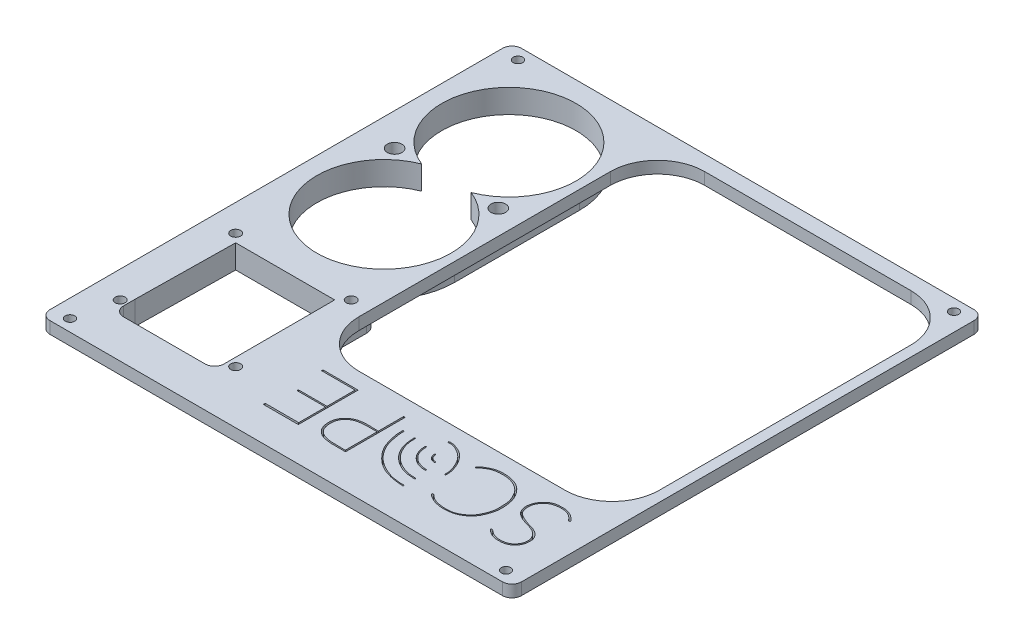
from build123d import *

# Parameters (mm, degrees)
SKETCH1_W           = 100
SKETCH1_H           = 100
BOSS_EXTRUDE1_DEPTH = 2.54
FILLET1_R           = 2
SKETCH5_R           = 1.55
SKETCH5_R_2         = 1.05000044
CUT_EXTRUDE1_DEPTH  = 71.756283113
SKETCH5_3_R         = 1.55
BOSS_EXTRUDE2_DEPTH = 5
FILLET2_R           = 2
SKETCH2_R           = 1
CUT_EXTRUDE2_DEPTH  = 10
CUT_EXTRUDE3_DEPTH  = 10
SKETCH5_7_R         = 1.05000044
BOSS_EXTRUDE3_DEPTH = 5


with BuildPart() as part:
    # Sketch1 → Boss-Extrude1 (new body)
    with BuildSketch(Plane.XZ):
        Rectangle(SKETCH1_W, SKETCH1_H)
    extrude(amount=-BOSS_EXTRUDE1_DEPTH)

    # Fillet1
    fillet1_edges = [part.edges().sort_by_distance(p)[0] for p in [
        (-50, 1.27, -50),
        (-50, 1.27, 50),
        (50, 1.27, -50),
        (50, 1.27, 50),
    ]]
    fillet(fillet1_edges, radius=FILLET1_R)

    # Sketch5 → Cut-Extrude1 (cut, through all)
    with BuildSketch(Plane(origin=(0, 2.54, 0), x_dir=(1, 0, 0), z_dir=(0, 1, 0))):
        Polygon((-42.5776419, -16.023961195), (-42.879081718, -37.046629817), (-42.879081718, -41.516382641), (-21.566564913, -41.516382641), (-21.566564913, -37.012848671), (-21.587138944, -16.01871878), align=None)
        with BuildLine():
            Line((47.785431882, -16.539966134), (47.785431882, 36.790287691))
            ThreePointArc((47.785431882, 36.790287691), (44.856499694, 43.861355503), (37.785431882, 46.790287691))
            Line((37.785431882, 46.790287691), (-5.931344626, 46.790287691))
            ThreePointArc((-5.931344626, 46.790287691), (-13.002412437, 43.861355503), (-15.931344626, 36.790287691))
            Line((-15.931344626, 36.790287691), (-15.931344626, -16.539966134))
            ThreePointArc((-15.931344626, -16.539966134), (-13.002412437, -23.611033946), (-5.931344626, -26.539966134))
            Line((-5.931344626, -26.539966134), (37.785431882, -26.539966134))
            ThreePointArc((37.785431882, -26.539966134), (44.856499694, -23.611033946), (47.785431882, -16.539966134))
        make_face()
        with BuildLine():
            ThreePointArc((-26.834003833, 18.175169755), (-32.078048073, 45.675169755), (-37.322092314, 18.175169755))
            ThreePointArc((-37.322092314, 18.175169755), (-32.078048073, -9.324830245), (-26.834003833, 18.175169755))
        make_face()
        with Locations((-21.078048073, 18.175169755)):
            Circle(SKETCH5_R)
        with Locations((-43.078048073, 18.175169755)):
            Circle(SKETCH5_R)
        with Locations((-44.328050243, -14.266383801)):
            Circle(SKETCH5_R_2)
        with Locations((-19.828045903, -14.266383801)):
            Circle(SKETCH5_R_2)
        with Locations((-19.828045903, -38.766383061)):
            Circle(SKETCH5_R_2)
        with Locations((-44.328050243, -38.766383061)):
            Circle(SKETCH5_R_2)
    extrude(amount=-CUT_EXTRUDE1_DEPTH, mode=Mode.SUBTRACT)

    # Sketch5_3 → Boss-Extrude2 (add)
    with BuildSketch(Plane(origin=(0, 2.54, 0), x_dir=(1, 0, 0), z_dir=(0, 1, 0))):
        with BuildLine():
            ThreePointArc((-47.078048073, 4.927463333), (-32.078048073, -10.072536667), (-17.078048073, 4.927463333))
            Line((-17.078048073, 4.927463333), (-17.078048073, 31.422876177))
            ThreePointArc((-17.078048073, 31.422876177), (-32.078048073, 46.422876177), (-47.078048073, 31.422876177))
            Line((-47.078048073, 31.422876177), (-47.078048073, 4.927463333))
        make_face()
        with Locations((-43.078048073, 18.175169755)):
            Circle(SKETCH5_3_R, mode=Mode.SUBTRACT)
        with BuildLine():
            ThreePointArc((-26.834003833, 18.175169755), (-32.078048073, -9.324830245), (-37.322092314, 18.175169755))
            ThreePointArc((-37.322092314, 18.175169755), (-32.078048073, 45.675169755), (-26.834003833, 18.175169755))
        make_face(mode=Mode.SUBTRACT)
        with Locations((-21.078048073, 18.175169755)):
            Circle(SKETCH5_3_R, mode=Mode.SUBTRACT)
    extrude(amount=-BOSS_EXTRUDE2_DEPTH)

    # Fillet2
    fillet2_edges = [part.edges().sort_by_distance(p)[0] for p in [
        (-21.566564913, 1.27, 41.516382641),
        (-42.879081718, 1.27, 41.516382641),
    ]]
    fillet(fillet2_edges, radius=FILLET2_R)

    # Sketch2 → Cut-Extrude2 (cut)
    with BuildSketch(Plane(origin=(0, 2.54, 0), x_dir=(1, 0, 0), z_dir=(0, 1, 0))):
        with Locations((-46.23, -47.5)):
            Circle(SKETCH2_R)
        with Locations((-46.23, 47.5)):
            Circle(SKETCH2_R)
        with Locations((46.23, 47.5)):
            Circle(SKETCH2_R)
        with Locations((46.23, -47.5)):
            Circle(SKETCH2_R)
    extrude(amount=-CUT_EXTRUDE2_DEPTH, mode=Mode.SUBTRACT)

    # Sketch5_6 → Cut-Extrude3 (cut)
    # profile 1 of 9: a face of its own
    with BuildSketch(Plane(origin=(0, 2.54, 0), x_dir=(1, 0, 0), z_dir=(0, 1, 0))):
        with BuildLine():
            Line((7.454971855, -42.756674081), (7.454971855, -30.099542868))
            Line((7.454971855, -30.099542868), (7.134000062, -30.099542868))
            Line((7.134000062, -30.099542868), (7.134000062, -35.48831502))
            add(Edge.make_bspline(
                [(7.454971855, -42.756674081), (6.016642015, -42.742807217), (4.157153025, -42.905685394), (2.03152803, -42.322191781), (1.190243452, -41.675771746), (0.495847342, -40.808178147), (0.253576355, -39.705632426), (0.230251501, -38.541279548), (0.560889802, -37.497632149), (1.363060181, -36.429131861), (3.508106693, -35.145579143), (5.734949759, -35.50553664), (7.134000062, -35.48831502)],
                knots=[0, 0, 0, 0, 0.238299864, 0.303826149, 0.357832803, 0.411015464, 0.484154472, 0.538966812, 0.602724426, 0.660596142, 0.756796473, 1, 1, 1, 1], degree=3))
        make_face()
        with BuildLine():
            add(Edge.make_bspline(
                [(7.134000062, -35.737544522), (5.903653829, -35.730537712), (4.432723119, -35.6637476), (2.565421314, -36.073513025), (1.474667315, -36.67382527), (0.621796107, -37.955147491), (0.592525711, -39.387812648), (0.777675824, -40.673281389), (1.601403355, -41.765992313), (2.652779361, -42.192864494), (4.489878002, -42.588954568), (5.960272181, -42.415098192), (7.134000062, -42.489049713)],
                knots=[0, 0, 0, 0, 0.221150248, 0.257458421, 0.339816601, 0.436924538, 0.514775346, 0.590341621, 0.664848203, 0.746014878, 0.786502907, 1, 1, 1, 1], degree=3))
            Line((7.134000062, -35.737544522), (7.134000062, -42.489049713))
        make_face(mode=Mode.SUBTRACT)
    # profile 2 of 9: a face of its own
    with BuildSketch(Plane(origin=(0, 2.54, 0), x_dir=(1, 0, 0), z_dir=(0, 1, 0))):
        Polygon((-9.982454946, -42.372442707), (-9.982454946, -42.762503277), (-2.550893142, -42.762503277), (-2.550893142, -30.099542868), (-9.982454946, -30.099542868), (-9.982454946, -30.403266248), (-2.864359651, -30.403266248), (-2.864359651, -36.366320928), (-8.915969676, -36.366320928), (-8.915969676, -36.653537303), (-2.864359651, -36.653537303), (-2.864359651, -42.372442707), align=None)
    # profile 3 of 9: a face of its own
    with BuildSketch(Plane(origin=(0, 2.54, 0), x_dir=(1, 0, 0), z_dir=(0, 1, 0))):
        with BuildLine():
            add(Edge.make_bspline(
                [(37.593181413, -41.643612831), (37.40967215, -41.507428823), (37.112471451, -41.306619314), (37.035696671, -41.661744246), (37.205055552, -41.750339093), (37.336756253, -41.876879626), (37.494635427, -42.0043491), (37.701472957, -42.193770155), (37.949247042, -42.352441563), (38.231991658, -42.511430393), (38.557023631, -42.626665217), (38.944594777, -42.753914152), (39.44060743, -42.847147117), (40.007537485, -42.835234425), (40.617918403, -42.847291665), (41.23249408, -42.712143885), (41.830731651, -42.509894871), (42.352498794, -42.151610177), (42.831871183, -41.673860926), (43.190054919, -41.079653056), (43.424424406, -40.373200618), (43.470917362, -39.668382921), (43.428355615, -38.850155289), (43.013927237, -38.16353088), (42.477236855, -37.577150257), (41.840505345, -37.198099844), (41.139736881, -36.898449848), (40.391831426, -36.714648378), (39.576764105, -36.462548762), (38.732228957, -36.082703253), (37.845470571, -35.679588902), (37.196833849, -35.014916166), (36.958765706, -34.135141272), (36.922484848, -33.252316932), (37.106138762, -32.230453223), (37.792231213, -31.339818622), (38.786166199, -30.498991508), (40.116093386, -30.243703176), (41.438372502, -30.226635142), (42.72039969, -30.645080339), (43.388869574, -31.324854202), (43.753535789, -31.758956411), (43.940738966, -31.837508945), (44.132581319, -31.616557037), (43.834268244, -31.264404879), (43.433185139, -30.95026451), (42.845965458, -30.475749956), (42.180954829, -30.196588232), (41.329850474, -29.957830521), (40.337062659, -29.968556934), (39.252184177, -30.046513568), (37.965696165, -30.655104141), (37.070414028, -31.712016703), (36.560713681, -33.220295149), (36.582521825, -34.509077453), (37.345777242, -35.635339372), (38.285361757, -36.25076813), (39.467146943, -36.685877056), (40.835314574, -37.041864204), (42.542437619, -37.75920346), (43.400589839, -39.662407355), (42.830660292, -41.201993993), (42.011865878, -42.104346956), (40.439021728, -42.71853319), (38.56013852, -42.509911065), (37.854474649, -41.837521081), (37.593181413, -41.643612831)],
                knots=[0, 0, 0, 0, 0.009560588, 0.011963369, 0.015856893, 0.018350853, 0.022115788, 0.026742157, 0.033549205, 0.03796876, 0.044280531, 0.052155793, 0.060064079, 0.071445208, 0.082789969, 0.092984367, 0.105348694, 0.11673613, 0.126897258, 0.141819673, 0.153829595, 0.166822344, 0.179944007, 0.197443935, 0.208751262, 0.222835841, 0.237084206, 0.249922192, 0.264461954, 0.283207703, 0.300033185, 0.317030511, 0.331288343, 0.348278283, 0.364825158, 0.386199831, 0.40765716, 0.433912129, 0.457189864, 0.479150551, 0.504672036, 0.507441522, 0.509853606, 0.514718318, 0.517533727, 0.532624654, 0.543734847, 0.557790643, 0.571412958, 0.591283685, 0.61118205, 0.629721771, 0.666983109, 0.681813944, 0.716027796, 0.731288022, 0.753878458, 0.775478411, 0.799297502, 0.830738335, 0.873011762, 0.895367423, 0.916616898, 0.936723293, 0.98638697, 1, 1, 1, 1], degree=3))
        make_face()
    # profile 4 of 9: a face of its own
    with BuildSketch(Plane(origin=(0, 2.54, 0), x_dir=(1, 0, 0), z_dir=(0, 1, 0))):
        with BuildLine():
            add(Edge.make_bspline(
                [(24.729519488, -41.310885688), (25.00335479, -41.51536573), (25.624614291, -42.133910316), (27.02074767, -42.50775471), (28.512076244, -42.650380596), (29.98802024, -42.572677012), (31.411793759, -41.891042168), (32.594205947, -40.965045382), (33.231007439, -39.900342432), (33.673853022, -38.853469583), (34.081138242, -37.649332635), (34.01614928, -36.073088557), (33.977822688, -34.534636943), (33.358134201, -33.173462162), (32.603035793, -31.857306344), (31.276273703, -30.872325384), (29.651522474, -30.31443196), (27.911040217, -30.223530132), (26.200119487, -30.462171368), (25.039024387, -31.185125894), (24.502539714, -31.673065491), (24.213600495, -31.962071076), (23.910728401, -31.741136203), (24.248806009, -31.633211748), (24.487068829, -31.177210302), (25.300021246, -30.762045667), (26.345639114, -30.175069716), (27.65664576, -29.936839347), (29.17897406, -29.966098283), (30.584508951, -30.26017694), (31.830877233, -30.841956891), (32.775815803, -31.722567581), (33.588893805, -32.819184517), (34.17987816, -34.263254416), (34.384149538, -35.785221779), (34.409630639, -37.40911294), (33.987811702, -38.872800026), (33.342075567, -40.475385125), (32.039718026, -41.853703345), (30.178809815, -42.721520827), (28.158477753, -42.894825616), (26.202135695, -42.638302171), (24.948138659, -41.955802113), (24.359516986, -41.495409594), (24.30095888, -41.276968542), (24.50481112, -41.151041867), (24.64184678, -41.245418164), (24.729519488, -41.310885688)],
                knots=[0, 0, 0, 0, 0.01648238, 0.047968568, 0.071025084, 0.096012434, 0.12397888, 0.152432236, 0.173422702, 0.188115115, 0.212208016, 0.239051825, 0.27024913, 0.291704276, 0.316630394, 0.349150093, 0.375530795, 0.405790912, 0.439797504, 0.464669708, 0.474694306, 0.47978403, 0.483415772, 0.486744837, 0.492832765, 0.51157285, 0.531041687, 0.5566909, 0.579693188, 0.610843976, 0.631219048, 0.65093332, 0.677881472, 0.702258748, 0.731817758, 0.757963831, 0.786737418, 0.810971685, 0.848072834, 0.882859304, 0.916289276, 0.95323014, 0.984635963, 0.989700298, 0.992295484, 0.994722905, 1, 1, 1, 1], degree=3))
        make_face()
    # profile 5 of 9: a face of its own
    with BuildSketch(Plane(origin=(0, 2.54, 0), x_dir=(1, 0, 0), z_dir=(0, 1, 0))):
        with BuildLine():
            add(Edge.make_bspline(
                [(22.097552278, -36.230765826), (22.097364976, -36.296524344), (22.096324668, -36.427918567), (22.32135312, -36.432330412), (22.350870169, -36.235596274), (22.343582714, -35.959915008), (22.314330044, -35.559653516), (22.25982758, -35.028826047), (22.025063724, -34.221369823), (21.56680291, -33.04462465), (20.660620777, -31.711812093), (19.540776894, -30.678798622), (18.404726665, -30.221205231), (17.547729958, -29.909954072), (16.969007106, -29.897589169), (16.54275495, -29.900613992), (16.482212439, -30.180687726), (16.953891586, -30.147626774), (17.442667064, -30.14023959), (18.069323369, -30.32702042), (18.911213472, -30.712001181), (19.976984053, -31.373727134), (21.032193712, -32.597246165), (21.637205095, -33.890265088), (22.069620078, -35.084435773), (22.098829679, -35.782292178), (22.097552278, -36.230765826)],
                knots=[0, 0, 0, 0, 0.00895538, 0.017375368, 0.023138375, 0.036378692, 0.062169446, 0.084489656, 0.119458989, 0.192259845, 0.279933149, 0.368490478, 0.42293577, 0.470763845, 0.505509557, 0.519792427, 0.526110802, 0.540472892, 0.570967771, 0.616574036, 0.634766356, 0.716029308, 0.808797952, 0.880668005, 0.938924234, 1, 1, 1, 1], degree=3))
        make_face()
    # profile 6 of 9: a face of its own
    with BuildSketch(Plane(origin=(0, 2.54, 0), x_dir=(1, 0, 0), z_dir=(0, 1, 0))):
        with BuildLine():
            add(Edge.make_bspline(
                [(18.750910861, -35.041883078), (18.675007774, -35.025546437), (18.437499094, -35.022365895), (18.066663029, -34.842647792), (17.710277453, -34.453903949), (17.54844683, -34.061649393), (17.571432225, -33.746230681), (17.479945241, -33.644213563), (17.358728823, -33.687443636), (17.338695099, -33.868079003), (17.33728945, -34.105590659), (17.440456849, -34.413549277), (17.614038679, -34.688713578), (17.821122218, -34.917603144), (18.037654094, -35.081731801), (18.262428952, -35.180160601), (18.510471904, -35.271840168), (18.921485214, -35.322200328), (18.910547622, -35.088830442), (18.821465021, -35.057068468), (18.750910861, -35.041883078)],
                knots=[0, 0, 0, 0, 0.042431055, 0.155316131, 0.230442776, 0.365572518, 0.398797737, 0.418108322, 0.437377401, 0.461930687, 0.519453455, 0.586671408, 0.654872104, 0.717820205, 0.773827097, 0.82085234, 0.862525208, 0.956121704, 0.960559082, 1, 1, 1, 1], degree=3))
        make_face()
    # profile 7 of 9: a face of its own
    with BuildSketch(Plane(origin=(0, 2.54, 0), x_dir=(1, 0, 0), z_dir=(0, 1, 0))):
        with BuildLine():
            add(Edge.make_bspline(
                [(19.383991983, -37.592961664), (19.353574467, -37.686724751), (18.70983148, -37.70761723), (18.142085789, -37.565445341), (17.268433654, -37.299317645), (16.629630287, -36.918023971), (16.060646532, -36.392547173), (15.573696915, -35.84837011), (15.272703384, -35.239449483), (15.070237743, -34.608881663), (14.914774869, -33.987722612), (14.915078684, -33.548962059), (14.91240762, -33.211242711), (15.175598037, -33.189968891), (15.170012102, -33.469543067), (15.161268264, -33.755791908), (15.236729483, -34.178134681), (15.294497696, -34.68438485), (15.522355152, -35.231773627), (15.801351506, -35.731097119), (16.173081724, -36.163619795), (16.590966017, -36.554470071), (17.155529985, -36.978957573), (17.976303683, -37.231019481), (18.721402006, -37.429319627), (19.176193491, -37.453166773), (19.391589987, -37.465420723), (19.396148505, -37.555488746), (19.383991983, -37.592961664)],
                knots=[0, 0, 0, 0, 0.020151489, 0.105514081, 0.145893646, 0.20934134, 0.262235197, 0.309762266, 0.363484694, 0.404474673, 0.451035881, 0.496238862, 0.503174171, 0.515699495, 0.532184053, 0.549198243, 0.581061492, 0.620566674, 0.657630693, 0.705642539, 0.741520942, 0.778030148, 0.827232584, 0.88933862, 0.959583717, 0.985999798, 0.99194635, 1, 1, 1, 1], degree=3))
        make_face()
    # profile 8 of 9: a face of its own
    with BuildSketch(Plane(origin=(0, 2.54, 0), x_dir=(1, 0, 0), z_dir=(0, 1, 0))):
        with BuildLine():
            add(Edge.make_bspline(
                [(19.548579196, -40.423847859), (17.986519357, -40.361666183), (16.316402702, -39.965577594), (13.77226486, -38.080112747), (12.671861048, -36.162566389), (12.25750067, -34.376217417), (12.246595096, -33.576530001), (12.181876817, -32.821114172), (12.406186586, -32.822575716), (12.431144633, -33.45410011), (12.444102428, -34.662352712), (13.295390392, -36.99075818), (15.164458019, -38.985636281), (17.541736985, -40.009072731), (18.853504928, -40.17013162), (19.804458145, -40.166554959), (19.814587732, -40.433129309), (19.662644745, -40.428388522), (19.548579196, -40.423847859)],
                knots=[0, 0, 0, 0, 0.151336469, 0.263514567, 0.370146189, 0.428428366, 0.480518787, 0.493763234, 0.496941915, 0.503824269, 0.557219436, 0.670714878, 0.789667151, 0.898787617, 0.97128939, 0.985682886, 0.988949029, 1, 1, 1, 1], degree=3))
        make_face()
    # profile 9 of 9: a face of its own
    with BuildSketch(Plane(origin=(0, 2.54, 0), x_dir=(1, 0, 0), z_dir=(0, 1, 0))):
        with BuildLine():
            add(Edge.make_bspline(
                [(17.835400902, -42.755838648), (18.31632741, -42.839733928), (18.782725593, -42.896094448), (19.92344639, -42.961775799), (19.816587819, -42.67062751), (19.469361112, -42.678012769), (19.06912238, -42.698642213), (18.07029756, -42.620430633), (16.843690504, -42.431096584), (15.22311372, -41.761840462), (13.881836697, -41.069198916), (12.178900487, -39.647226915), (10.750581178, -37.711611727), (10.172884264, -35.408199132), (9.921346426, -33.90270265), (9.911244628, -33.207634376), (9.913385662, -32.754154597), (9.621408296, -32.759483161), (9.648029064, -33.14220836), (9.643397879, -33.612856382), (9.691269158, -34.43541429), (9.998526042, -35.827655199), (10.557958396, -37.771557011), (11.885307371, -39.563536762), (13.338266034, -40.974852602), (14.960580646, -41.997342595), (16.506727187, -42.502148738), (17.549309412, -42.705931386), (17.835400902, -42.755838648)],
                knots=[0, 0, 0, 0, 0.049570596, 0.063668495, 0.066267319, 0.074587303, 0.090482095, 0.106620435, 0.1660965, 0.205866204, 0.26907374, 0.305514066, 0.411979434, 0.484112923, 0.52761574, 0.548360426, 0.55632757, 0.560848141, 0.568708515, 0.584020049, 0.609687825, 0.642484525, 0.717886353, 0.794947643, 0.846631834, 0.906204935, 0.970511658, 1, 1, 1, 1], degree=3))
        make_face()
    extrude(amount=-CUT_EXTRUDE3_DEPTH, mode=Mode.SUBTRACT)


with BuildPart() as cut_extrude3_piece_1:
    # of the separate pieces the step leaves, piece 1, a body of its own (cut_extrude3_pieces)
    add(part.part.solids().sort_by_distance((-48, 2.54, -50))[0])

    # Sketch5_7 → Boss-Extrude3 (add)
    with BuildSketch(Plane(origin=(0, 2.54, 0), x_dir=(1, 0, 0), z_dir=(0, 1, 0))):
        with BuildLine():
            ThreePointArc((-44.828052363, -11.510447223), (-46.419042621, -12.169456966), (-47.078052363, -13.760447223))
            Line((-47.078052363, -13.760447223), (-47.078052363, -39.266382641))
            ThreePointArc((-47.078052363, -39.266382641), (-46.419042621, -40.857372898), (-44.828052363, -41.516382641))
            Line((-44.828052363, -41.516382641), (-42.879081718, -41.516382641))
            Line((-42.879081718, -41.516382641), (-42.879081718, -37.046629817))
            Line((-42.879081718, -37.046629817), (-42.5776419, -16.023961195))
            Line((-42.5776419, -16.023961195), (-21.587138944, -16.01871878))
            Line((-21.587138944, -16.01871878), (-21.566564913, -37.012848671))
            Line((-21.566564913, -37.012848671), (-21.566564913, -41.516382641))
            Line((-21.566564913, -41.516382641), (-19.328051403, -41.516382641))
            ThreePointArc((-19.328051403, -41.516382641), (-17.737061146, -40.857372898), (-17.078051403, -39.266382641))
            Line((-17.078051403, -39.266382641), (-17.078051403, -13.760447223))
            ThreePointArc((-17.078051403, -13.760447223), (-17.737061146, -12.169456966), (-19.328051403, -11.510447223))
            Line((-19.328051403, -11.510447223), (-44.828052363, -11.510447223))
        make_face()
        with Locations((-44.328050243, -14.266383801)):
            Circle(SKETCH5_7_R, mode=Mode.SUBTRACT)
        with Locations((-19.828045903, -14.266383801)):
            Circle(SKETCH5_7_R, mode=Mode.SUBTRACT)
        with Locations((-19.828045903, -38.766383061)):
            Circle(SKETCH5_7_R, mode=Mode.SUBTRACT)
        with Locations((-44.328050243, -38.766383061)):
            Circle(SKETCH5_7_R, mode=Mode.SUBTRACT)
    extrude(amount=-BOSS_EXTRUDE3_DEPTH)


with BuildPart() as cut_extrude3_piece_2:
    # of the separate pieces the step leaves, piece 2, a body of its own (cut_extrude3_pieces)
    add(part.part.solids().sort_by_distance((7.134000062, 2.54, 42.489049713))[0])


solid = Compound([cut_extrude3_piece_1.part, cut_extrude3_piece_2.part])
